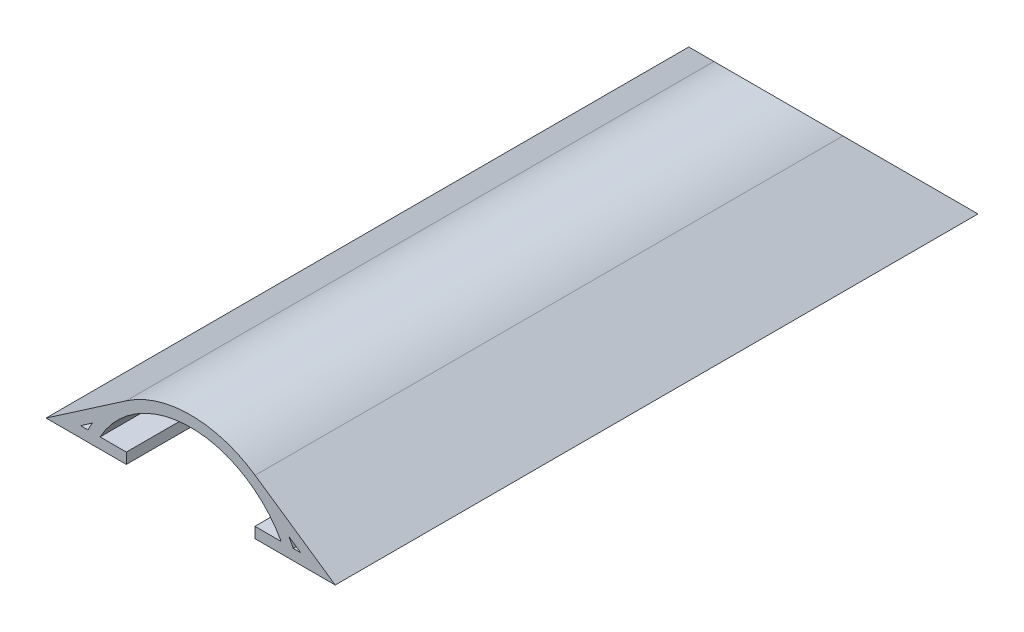
from build123d import *

# Parameters (mm, degrees)
BOSS_EXTRUDE1_DEPTH = 152.4
CUT_EXTRUDE1_DEPTH  = 69.58
CUT_EXTRUDE2_REACH  = 19.78
SKETCH4_W           = 30.48
SKETCH4_H           = 38.1


with BuildPart() as part:
    # Sketch2 → Boss-Extrude1 (new body)
    with BuildSketch(Plane.XY):
        with BuildLine():
            Line((0, 0), (68.58, 0))
            Line((68.58, 0), (49.587320143, 13.03542143))
            ThreePointArc((49.587320143, 13.03542143), (34.29, 17.78), (18.992679857, 13.03542143))
            Line((18.992679857, 13.03542143), (0, 0))
        make_face()
        with BuildLine():
            Line((10.997802271, 4.46752515), (8.189387654, 2.54))
            Line((8.189387654, 2.54), (9.965035751, 2.54))
            ThreePointArc((9.965035751, 2.54), (10.461920618, 3.514209799), (10.997802271, 4.46752515))
        make_face(mode=Mode.SUBTRACT)
        with BuildLine():
            Line((57.582197729, 4.46752515), (60.390612346, 2.54))
            Line((60.390612346, 2.54), (58.614964249, 2.54))
            ThreePointArc((58.614964249, 2.54), (58.118079382, 3.514209799), (57.582197729, 4.46752515))
        make_face(mode=Mode.SUBTRACT)
        with BuildLine():
            Line((12.82308193, 2.54), (55.75691807, 2.54))
            ThreePointArc((55.75691807, 2.54), (34.29, 15.24), (12.82308193, 2.54))
        make_face(mode=Mode.SUBTRACT)
    extrude(amount=BOSS_EXTRUDE1_DEPTH)

    # Sketch3 → Cut-Extrude1 (cut, through all)
    with BuildSketch(Plane(origin=(0, 0, 0), x_dir=(0, 0, -1), z_dir=(1, 0, 0))):
        Polygon((-17.78, 17.78), (0, 0), (0, 17.78), align=None)
    extrude(amount=CUT_EXTRUDE1_DEPTH, mode=Mode.SUBTRACT)

    # Sketch4 → Cut-Extrude2 (cut, up to next)
    with BuildSketch(Plane.XZ, mode=Mode.PRIVATE) as cut_extrude2_sk1:
        with Locations((34.29, 133.35)):
            Rectangle(SKETCH4_W, SKETCH4_H)
    cut_extrude2_tool1 = extrude(cut_extrude2_sk1.sketch, amount=-CUT_EXTRUDE2_REACH, mode=Mode.PRIVATE) & part.part
    add(cut_extrude2_tool1.solids().sort_by_distance((34.29, 0, 133.35))[0], mode=Mode.SUBTRACT)


solid = part.part
